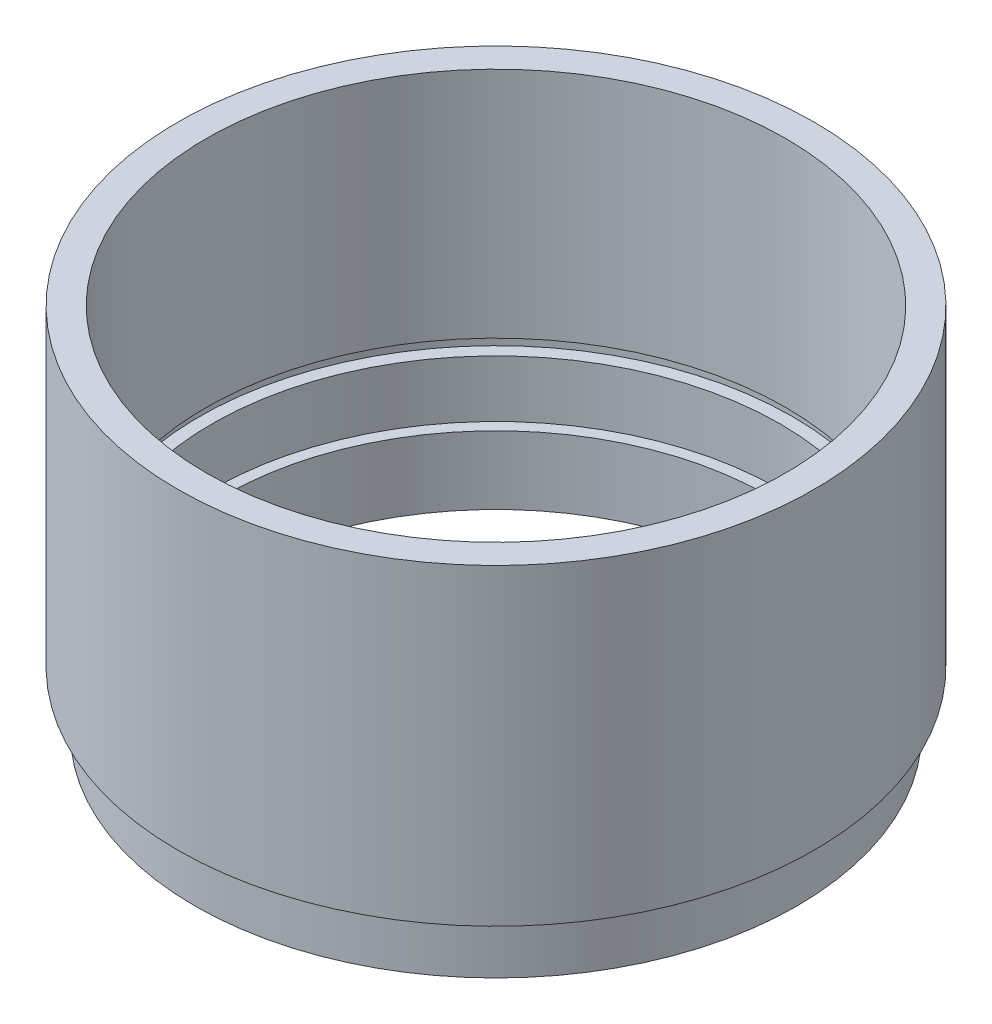
from build123d import *


with BuildPart() as part:
    # 草图1 → 旋转1 (revolve)
    with BuildSketch(Plane.XY, mode=Mode.PRIVATE) as revolve_1_sk:
        Polygon((24, 0), (26.5, 0), (26.5, 4), (25.5, 4), (25.5, 5), (28, 5), (28, 32.5), (25.5, 32.5), (25.5, 12), (26.1, 12), (26.1, 11), (25, 11), (25, 6), (24, 6), align=None)
    revolve(revolve_1_sk.sketch.rotate(Axis((0, 0, 0), (0, 1, 0)), 90), axis=Axis((0, 0, 0), (0, 1, 0)))  # turned: the seam where the file's is


solid = part.part
